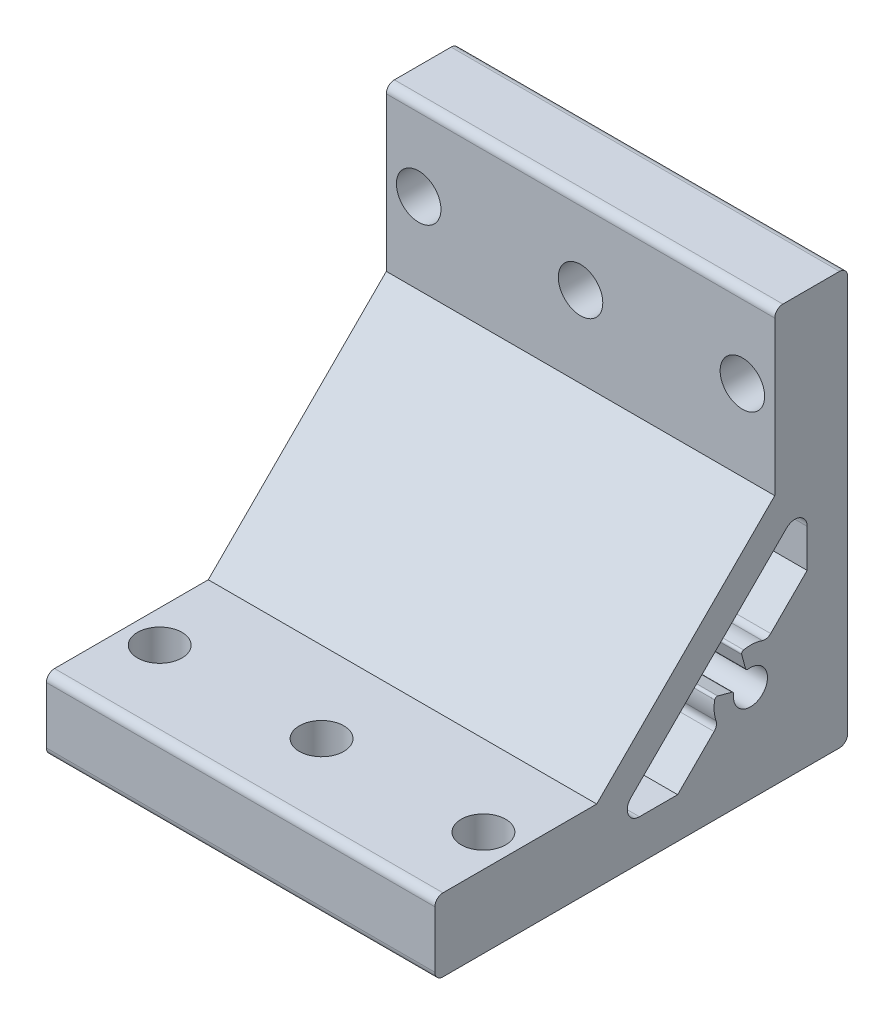
from build123d import *

# Parameters (mm, degrees)
BOSS_EXTRUDE1_DEPTH      = 24
BOSS_EXTRUDE1_DEPTH_BACK = 24
SKETCH2_R                = 2.75
CUT_EXTRUDE1_DEPTH       = 9
SKETCH3_R                = 2.75
CUT_EXTRUDE2_DEPTH       = 9
SKETCH4_R                = 2.75
CUT_EXTRUDE3_DEPTH       = 9
SKETCH5_R                = 2.75
CUT_EXTRUDE4_DEPTH       = 9
SKETCH6_R                = 2.75
CUT_EXTRUDE5_DEPTH       = 10
SKETCH7_R                = 2.75
CUT_EXTRUDE6_DEPTH       = 10


with BuildPart() as part:
    # Sketch1 → Boss-Extrude1 (new, two sides: drawn at the far end of the back side and taken through both)
    with BuildSketch(Plane(origin=(0, 0, 0), x_dir=(0, 0, -1), z_dir=(1, 0, 0)).offset(-BOSS_EXTRUDE1_DEPTH_BACK)):
        with BuildLine():
            Line((-50, 0), (-1, 0))
            ThreePointArc((-1, 0), (-0.292893219, 0.292893219), (0, 1))
            Line((0, 1), (0, 50))
            ThreePointArc((0, 50), (-0.292893219, 50.707106781), (-1, 51))
            Line((-1, 51), (-8, 51))
            ThreePointArc((-8, 51), (-8.707106781, 50.707106781), (-9, 50))
            Line((-9, 50), (-9, 31))
            Line((-9, 31), (-31, 9))
            Line((-31, 9), (-50, 9))
            ThreePointArc((-50, 9), (-50.707106781, 8.707106781), (-51, 8))
            Line((-51, 8), (-51, 1))
            ThreePointArc((-51, 1), (-50.707106781, 0.292893219), (-50, 0))
        make_face()
        with BuildLine():
            Line((-25.721825407, 5), (-20.999285733, 5))
            Line((-20.999285733, 5), (-16.494036438, 9.505249294))
            ThreePointArc((-16.494036438, 9.505249294), (-16.226979866, 9.987090789), (-16.255625497, 10.537245192))
            ThreePointArc((-16.255625497, 10.537245192), (-16.488859314, 11.683547702), (-16.418755424, 12.851234691))
            ThreePointArc((-16.418755424, 12.851234691), (-16.283360667, 13.048766752), (-16.046526031, 13.084263382))
            Line((-16.046526031, 13.084263382), (-14.300039569, 12.616293745))
            ThreePointArc((-14.300039569, 12.616293745), (-14.127781033, 12.492491496), (-14.080474622, 12.285701498))
            ThreePointArc((-14.080474622, 12.285701498), (-10.515075745, 10.515075774), (-12.285701539, 14.080474617))
            ThreePointArc((-12.285701539, 14.080474617), (-12.492491514, 14.127781045), (-12.616293745, 14.300039569))
            Line((-12.616293745, 14.300039569), (-13.084263382, 16.046526031))
            ThreePointArc((-13.084263382, 16.046526031), (-13.048766728, 16.283360705), (-12.851234602, 16.418755442))
            ThreePointArc((-12.851234602, 16.418755442), (-11.683774102, 16.488875269), (-10.537674556, 16.255773055))
            ThreePointArc((-10.537674556, 16.255773055), (-9.987311976, 16.226928716), (-9.505249294, 16.494036438))
            Line((-9.505249294, 16.494036438), (-5, 20.999285733))
            Line((-5, 20.999285733), (-5, 25.721825407))
            ThreePointArc((-5, 25.721825407), (-5.925974851, 27.107644706), (-7.560660172, 26.782485579))
            Line((-7.560660172, 26.782485579), (-26.782485579, 7.560660172))
            ThreePointArc((-26.782485579, 7.560660172), (-27.107644706, 5.925974851), (-25.721825407, 5))
        make_face(mode=Mode.SUBTRACT)
    extrude(amount=BOSS_EXTRUDE1_DEPTH + BOSS_EXTRUDE1_DEPTH_BACK)

    # Sketch2 → Cut-Extrude1 (cut)
    with BuildSketch(Plane(origin=(0, 0, 0), x_dir=(-1, 0, 0), z_dir=(0, 1, 0))):
        with Locations((20, 41)):
            Circle(SKETCH2_R)
    extrude(amount=CUT_EXTRUDE1_DEPTH, mode=Mode.SUBTRACT)

    # Sketch3 → Cut-Extrude2 (cut)
    with BuildSketch(Plane(origin=(0, 0, 0), x_dir=(-1, 0, 0), z_dir=(0, 1, 0))):
        with Locations((-20, 41)):
            Circle(SKETCH3_R)
    extrude(amount=CUT_EXTRUDE2_DEPTH, mode=Mode.SUBTRACT)

    # Sketch4 → Cut-Extrude3 (cut)
    with BuildSketch(Plane.XY):
        with Locations((-20, 41)):
            Circle(SKETCH4_R)
    extrude(amount=CUT_EXTRUDE3_DEPTH, mode=Mode.SUBTRACT)

    # Sketch5 → Cut-Extrude4 (cut)
    with BuildSketch(Plane.XY):
        with Locations((20, 41)):
            Circle(SKETCH5_R)
    extrude(amount=CUT_EXTRUDE4_DEPTH, mode=Mode.SUBTRACT)

    # Sketch6 → Cut-Extrude5 (cut)
    with BuildSketch(Plane(origin=(0, 9, 0), x_dir=(1, 0, 0), z_dir=(0, 1, 0))):
        with Locations((0, -41)):
            Circle(SKETCH6_R)
    extrude(amount=-CUT_EXTRUDE5_DEPTH, mode=Mode.SUBTRACT)

    # Sketch7 → Cut-Extrude6 (cut)
    with BuildSketch(Plane.XY.offset(9)):
        with Locations((0, 41)):
            Circle(SKETCH7_R)
    extrude(amount=-CUT_EXTRUDE6_DEPTH, mode=Mode.SUBTRACT)


solid = part.part
